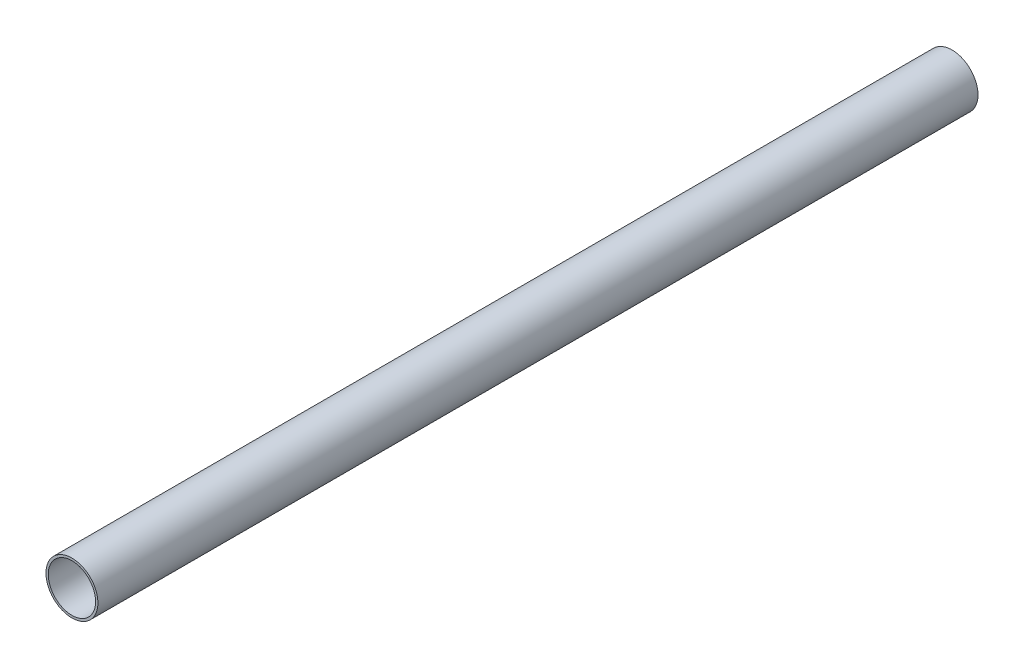
from build123d import *

# Parameters (mm, degrees)
PIPESKETCH_R    = 161.925
PIPESKETCH_R_2  = 147.6502
EXTRUSION_DEPTH = 5486.4


with BuildPart() as part:
    # PipeSketch → Extrusion (new body)
    with BuildSketch(Plane.XY):
        Circle(PIPESKETCH_R)
        Circle(PIPESKETCH_R_2, mode=Mode.SUBTRACT)
    extrude(amount=EXTRUSION_DEPTH)


solid = part.part
